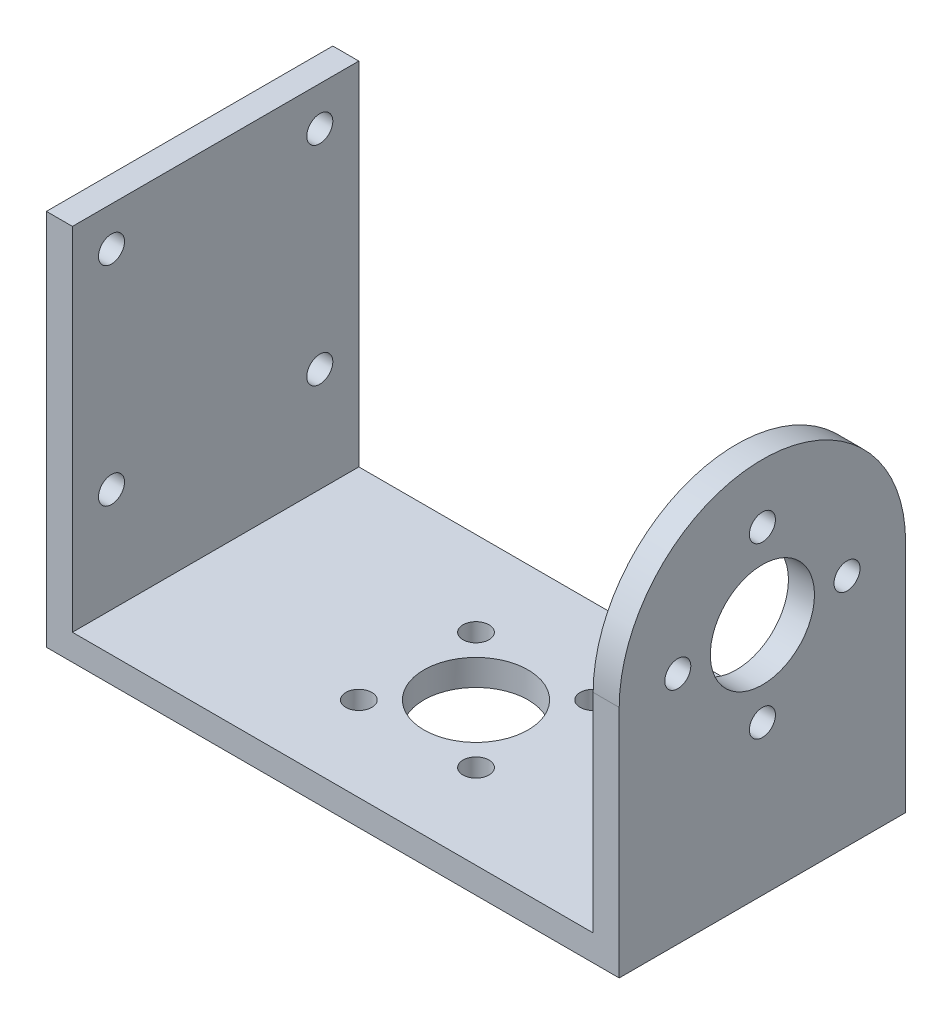
from build123d import *

# Parameters (mm, degrees)
SKETCH1_W           = 44
SKETCH1_H           = 22
BOSS_EXTRUDE1_DEPTH = 2
SKETCH2_W           = 2
SKETCH2_H           = 22
BOSS_EXTRUDE2_DEPTH = 27
CUT_EXTRUDE1_REACH  = 46
CUT_EXTRUDE2_REACH  = 46
SKETCH4_R           = 1
CUT_EXTRUDE3_REACH  = 46
SKETCH5_R           = 4
SKETCH5_R_2         = 1
SKETCH6_R           = 1
SKETCH6_R_2         = 4
CUT_EXTRUDE4_DEPTH  = 5


with BuildPart() as part:
    # Sketch1 → Boss-Extrude1 (new body)
    with BuildSketch(Plane(origin=(0, 0, 0), x_dir=(1, 0, 0), z_dir=(0, 1, 0))):
        with Locations((22, 11)):
            Rectangle(SKETCH1_W, SKETCH1_H)
    extrude(amount=BOSS_EXTRUDE1_DEPTH)

    # Sketch2 → Boss-Extrude2 (add)
    with BuildSketch(Plane(origin=(0, 2, 0), x_dir=(1, 0, 0), z_dir=(0, 1, 0))):
        with Locations((1, 11)):
            Rectangle(SKETCH2_W, SKETCH2_H)
        with Locations((43, 11)):
            Rectangle(SKETCH2_W, SKETCH2_H)
    extrude(amount=BOSS_EXTRUDE2_DEPTH)

    # Sketch3 → Cut-Extrude1 (cut, up to next)
    with BuildSketch(Plane(origin=(44, 0, 0), x_dir=(0, 0, -1), z_dir=(1, 0, 0)), mode=Mode.PRIVATE) as cut_extrude1_sk1:
        with BuildLine():
            Line((11, 29), (0, 29))
            Line((0, 29), (0, 18))
            ThreePointArc((0, 18), (3.221825407, 25.778174593), (11, 29))
        make_face()
    cut_extrude1_tool1 = extrude(cut_extrude1_sk1.sketch, amount=-CUT_EXTRUDE1_REACH, mode=Mode.PRIVATE) & part.part
    add(cut_extrude1_tool1.solids().sort_by_distance((44, 26.542953, -2.457047))[0], mode=Mode.SUBTRACT)
    # Sketch3 → Cut-Extrude1 (cut, up to next)
    with BuildSketch(Plane(origin=(44, 0, 0), x_dir=(0, 0, -1), z_dir=(1, 0, 0)), mode=Mode.PRIVATE) as cut_extrude1_sk2:
        with BuildLine():
            Line((22, 29), (11, 29))
            ThreePointArc((11, 29), (18.778174593, 25.778174593), (22, 18))
            Line((22, 18), (22, 29))
        make_face()
    cut_extrude1_tool2 = extrude(cut_extrude1_sk2.sketch, amount=-CUT_EXTRUDE1_REACH, mode=Mode.PRIVATE) & part.part
    add(cut_extrude1_tool2.solids().sort_by_distance((44, 26.542953, -19.542953))[0], mode=Mode.SUBTRACT)

    # Sketch4 → Cut-Extrude2 (cut, up to next)
    with BuildSketch(Plane.ZY, mode=Mode.PRIVATE) as cut_extrude2_sk1:
        with Locations((-19, 10)):
            Circle(SKETCH4_R)
    cut_extrude2_tool1 = extrude(cut_extrude2_sk1.sketch, amount=-CUT_EXTRUDE2_REACH, mode=Mode.PRIVATE) & part.part
    add(cut_extrude2_tool1.solids().sort_by_distance((0, 10, -19))[0], mode=Mode.SUBTRACT)
    # Sketch4 → Cut-Extrude2 (cut, up to next)
    with BuildSketch(Plane.ZY, mode=Mode.PRIVATE) as cut_extrude2_sk2:
        with Locations((-19, 26)):
            Circle(SKETCH4_R)
    cut_extrude2_tool2 = extrude(cut_extrude2_sk2.sketch, amount=-CUT_EXTRUDE2_REACH, mode=Mode.PRIVATE) & part.part
    add(cut_extrude2_tool2.solids().sort_by_distance((0, 26, -19))[0], mode=Mode.SUBTRACT)
    # Sketch4 → Cut-Extrude2 (cut, up to next)
    with BuildSketch(Plane.ZY, mode=Mode.PRIVATE) as cut_extrude2_sk3:
        with Locations((-3, 10)):
            Circle(SKETCH4_R)
    cut_extrude2_tool3 = extrude(cut_extrude2_sk3.sketch, amount=-CUT_EXTRUDE2_REACH, mode=Mode.PRIVATE) & part.part
    add(cut_extrude2_tool3.solids().sort_by_distance((0, 10, -3))[0], mode=Mode.SUBTRACT)
    # Sketch4 → Cut-Extrude2 (cut, up to next)
    with BuildSketch(Plane.ZY, mode=Mode.PRIVATE) as cut_extrude2_sk4:
        with Locations((-3, 26)):
            Circle(SKETCH4_R)
    cut_extrude2_tool4 = extrude(cut_extrude2_sk4.sketch, amount=-CUT_EXTRUDE2_REACH, mode=Mode.PRIVATE) & part.part
    add(cut_extrude2_tool4.solids().sort_by_distance((0, 26, -3))[0], mode=Mode.SUBTRACT)

    # Sketch5 → Cut-Extrude3 (cut, up to next)
    with BuildSketch(Plane(origin=(44, 0, 0), x_dir=(0, 0, -1), z_dir=(1, 0, 0)), mode=Mode.PRIVATE) as cut_extrude3_sk1:
        with Locations((11, 18)):
            Circle(SKETCH5_R)
    cut_extrude3_tool1 = extrude(cut_extrude3_sk1.sketch, amount=-CUT_EXTRUDE3_REACH, mode=Mode.PRIVATE) & part.part
    add(cut_extrude3_tool1.solids().sort_by_distance((44, 18, -11))[0], mode=Mode.SUBTRACT)
    # Sketch5 → Cut-Extrude3 (cut, up to next)
    with BuildSketch(Plane(origin=(44, 0, 0), x_dir=(0, 0, -1), z_dir=(1, 0, 0)), mode=Mode.PRIVATE) as cut_extrude3_sk2:
        with Locations((17.5, 18)):
            Circle(SKETCH5_R_2)
    cut_extrude3_tool2 = extrude(cut_extrude3_sk2.sketch, amount=-CUT_EXTRUDE3_REACH, mode=Mode.PRIVATE) & part.part
    add(cut_extrude3_tool2.solids().sort_by_distance((44, 18, -17.5))[0], mode=Mode.SUBTRACT)
    # Sketch5 → Cut-Extrude3 (cut, up to next)
    with BuildSketch(Plane(origin=(44, 0, 0), x_dir=(0, 0, -1), z_dir=(1, 0, 0)), mode=Mode.PRIVATE) as cut_extrude3_sk3:
        with Locations((11, 24.5)):
            Circle(SKETCH5_R_2)
    cut_extrude3_tool3 = extrude(cut_extrude3_sk3.sketch, amount=-CUT_EXTRUDE3_REACH, mode=Mode.PRIVATE) & part.part
    add(cut_extrude3_tool3.solids().sort_by_distance((44, 24.5, -11))[0], mode=Mode.SUBTRACT)
    # Sketch5 → Cut-Extrude3 (cut, up to next)
    with BuildSketch(Plane(origin=(44, 0, 0), x_dir=(0, 0, -1), z_dir=(1, 0, 0)), mode=Mode.PRIVATE) as cut_extrude3_sk4:
        with Locations((4.5, 18)):
            Circle(SKETCH5_R_2)
    cut_extrude3_tool4 = extrude(cut_extrude3_sk4.sketch, amount=-CUT_EXTRUDE3_REACH, mode=Mode.PRIVATE) & part.part
    add(cut_extrude3_tool4.solids().sort_by_distance((44, 18, -4.5))[0], mode=Mode.SUBTRACT)
    # Sketch5 → Cut-Extrude3 (cut, up to next)
    with BuildSketch(Plane(origin=(44, 0, 0), x_dir=(0, 0, -1), z_dir=(1, 0, 0)), mode=Mode.PRIVATE) as cut_extrude3_sk5:
        with Locations((11, 11.5)):
            Circle(SKETCH5_R_2)
    cut_extrude3_tool5 = extrude(cut_extrude3_sk5.sketch, amount=-CUT_EXTRUDE3_REACH, mode=Mode.PRIVATE) & part.part
    add(cut_extrude3_tool5.solids().sort_by_distance((44, 11.5, -11))[0], mode=Mode.SUBTRACT)

    # Sketch6 → Cut-Extrude4 (cut)
    with BuildSketch(Plane(origin=(0, 2, 0), x_dir=(1, 0, 0), z_dir=(0, 1, 0))):
        with BuildLine():
            ThreePointArc((26.5, 7.5), (25.792893219, 7.207106781), (25.5, 6.5))
            Line((25.5, 6.5), (26.5, 6.5))
            Line((26.5, 6.5), (26.5, 7.5))
        make_face()
        with BuildLine():
            Line((26.5, 6.5), (25.5, 6.5))
            ThreePointArc((25.5, 6.5), (26.5, 5.5), (27.5, 6.5))
            ThreePointArc((27.5, 6.5), (27.207106781, 7.207106781), (26.5, 7.5))
            Line((26.5, 7.5), (26.5, 6.5))
        make_face()
        with Locations((17.5, 6.5)):
            Circle(SKETCH6_R)
        with Locations((17.5, 15.5)):
            Circle(SKETCH6_R)
        with Locations((26.5, 15.5)):
            Circle(SKETCH6_R)
        with Locations((22, 11)):
            Circle(SKETCH6_R_2)
    extrude(amount=-CUT_EXTRUDE4_DEPTH, mode=Mode.SUBTRACT)


solid = part.part
